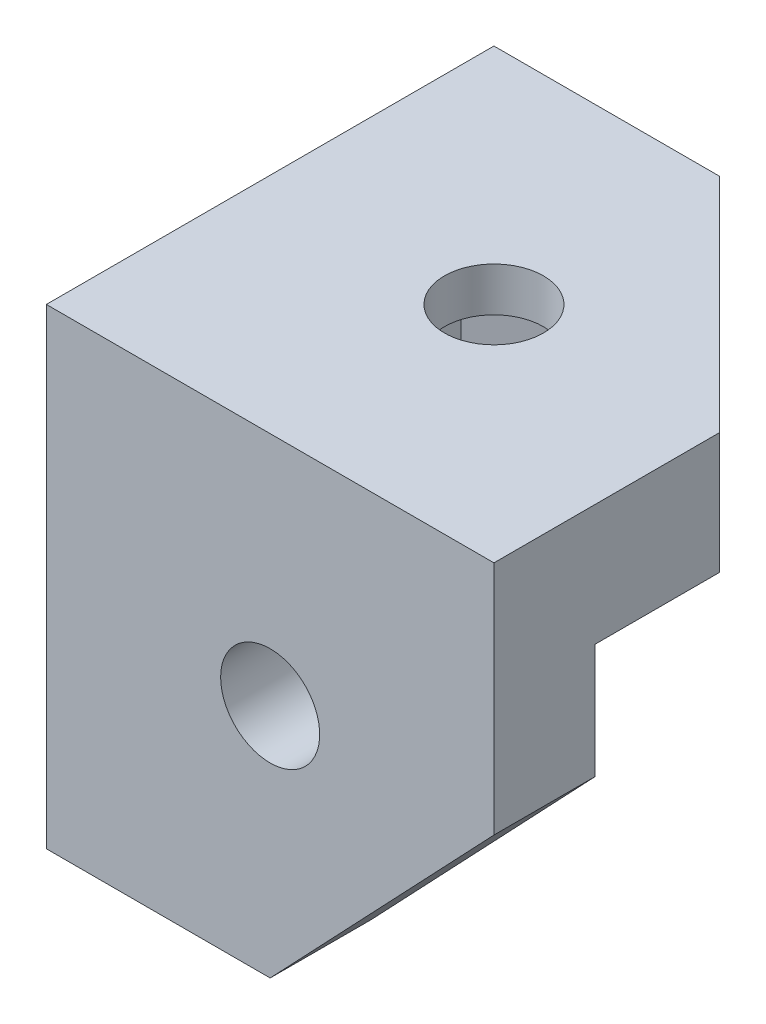
from build123d import *

# Parameters (mm, degrees)
SKETCH1_W                    = 32.28
SKETCH1_H                    = 32.28
MAIN_BODY_DEPTH              = 34
SKETCH3_R                    = 3.571875
F_9_32_RIGHT_RAIL_DEPTH      = 1
F_9_32_RIGHT_RAIL_DEPTH_BACK = 8.334375
SKETCH4_R                    = 3.571875
F_9_32_LEFT_RAIL_DEPTH       = 8.334375
SKETCH8_R                    = 3.571875
F_9_32_TOPPER_DEPTH          = 1
F_9_32_TOPPER_DEPTH_BACK     = 10
INNER_START                  = -17.4625
SKETCH13_W                   = 24.987421875
SKETCH13_H                   = 24.987421875
INNER_CAVITY_DEPTH           = 8.73125
INNER_CAVITY_DEPTH_BACK      = 34
HEX_START                    = -17
HEX_HOLE_TOP_DEPTH           = 13.825
TOP_CORNER_REACH             = 36
CUT_EXTRUDE2_DEPTH           = 7.292578
CUT_EXTRUDE3_DEPTH           = 7.292578


with BuildPart() as part:
    # Sketch1 → Main Body (new body)
    with BuildSketch(Plane(origin=(0, 0, 0), x_dir=(1, 0, 0), z_dir=(0, 1, 0))):
        with Locations((16.14, 16.14)):
            Rectangle(SKETCH1_W, SKETCH1_H)
    extrude(amount=MAIN_BODY_DEPTH)

    # Sketch3 → 9_32 Right Rail (cut, two sides)
    with BuildSketch(Plane.XY) as f_9_32_right_rail_sk:
        with Locations((16.14, 17)):
            Circle(SKETCH3_R)
    extrude(amount=F_9_32_RIGHT_RAIL_DEPTH, mode=Mode.SUBTRACT)
    extrude(f_9_32_right_rail_sk.sketch, amount=-F_9_32_RIGHT_RAIL_DEPTH_BACK, mode=Mode.SUBTRACT)

    # Sketch4 → 9_32 Left Rail (cut)
    with BuildSketch(Plane.ZY):
        with Locations((-16.14, 17)):
            Circle(SKETCH4_R)
    extrude(amount=-F_9_32_LEFT_RAIL_DEPTH, mode=Mode.SUBTRACT)

    # Sketch8 → 9_32 Topper (cut, two sides)
    with BuildSketch(Plane(origin=(0, 34, 0), x_dir=(1, 0, 0), z_dir=(0, 1, 0))) as f_9_32_topper_sk:
        with Locations((16.14, 16.14)):
            Circle(SKETCH8_R)
    extrude(amount=F_9_32_TOPPER_DEPTH, mode=Mode.SUBTRACT)
    extrude(f_9_32_topper_sk.sketch, amount=-F_9_32_TOPPER_DEPTH_BACK, mode=Mode.SUBTRACT)

    # Sketch13 → Inner Cavity (cut, two sides)
    with BuildSketch(Plane(origin=(0, 34, 0), x_dir=(1, 0, 0), z_dir=(0, 1, 0)).offset(INNER_START)) as inner_cavity_sk:
        with Locations((19.786289062, 19.786289062)):
            Rectangle(SKETCH13_W, SKETCH13_H)
    extrude(amount=INNER_CAVITY_DEPTH, mode=Mode.SUBTRACT)
    extrude(inner_cavity_sk.sketch, amount=-INNER_CAVITY_DEPTH_BACK, mode=Mode.SUBTRACT)

    # Sketch14 → Hex Hole Top (cut)
    with BuildSketch(Plane(origin=(0, 34, 0), x_dir=(1, 0, 0), z_dir=(0, 1, 0)).offset(HEX_START)):
        Polygon((21.79546875, 19.405186405), (16.14, 22.67037281), (10.48453125, 19.405186405), (10.48453125, 12.874813595), (16.14, 9.60962719), (21.79546875, 12.874813595), align=None)
    extrude(amount=HEX_HOLE_TOP_DEPTH, mode=Mode.SUBTRACT)

    # Sketch16 → Top Corner (cut, up to next)
    with BuildSketch(Plane(origin=(0, 34, 0), x_dir=(1, 0, 0), z_dir=(0, 1, 0)), mode=Mode.PRIVATE) as top_corner_sk1:
        Polygon((32.28, 32.28), (16.276714219, 32.28), (32.28, 16.276714219), align=None)
    top_corner_tool1 = extrude(top_corner_sk1.sketch, amount=-TOP_CORNER_REACH, mode=Mode.PRIVATE) & part.part
    add(top_corner_tool1.solids().sort_by_distance((26.945571, 34, -26.945571))[0], mode=Mode.SUBTRACT)

    # Sketch18 → Cut-Extrude2 (cut)
    with BuildSketch(Plane.ZY):
        Polygon((-32.28, 0), (-16.14, 0), (-32.28, 17), align=None)
    extrude(amount=-CUT_EXTRUDE2_DEPTH, mode=Mode.SUBTRACT)

    # Sketch19 → Cut-Extrude3 (cut)
    with BuildSketch(Plane.XY):
        Polygon((32.28, 0), (16.14, 0), (32.28, 17), align=None)
    extrude(amount=-CUT_EXTRUDE3_DEPTH, mode=Mode.SUBTRACT)


solid = part.part
